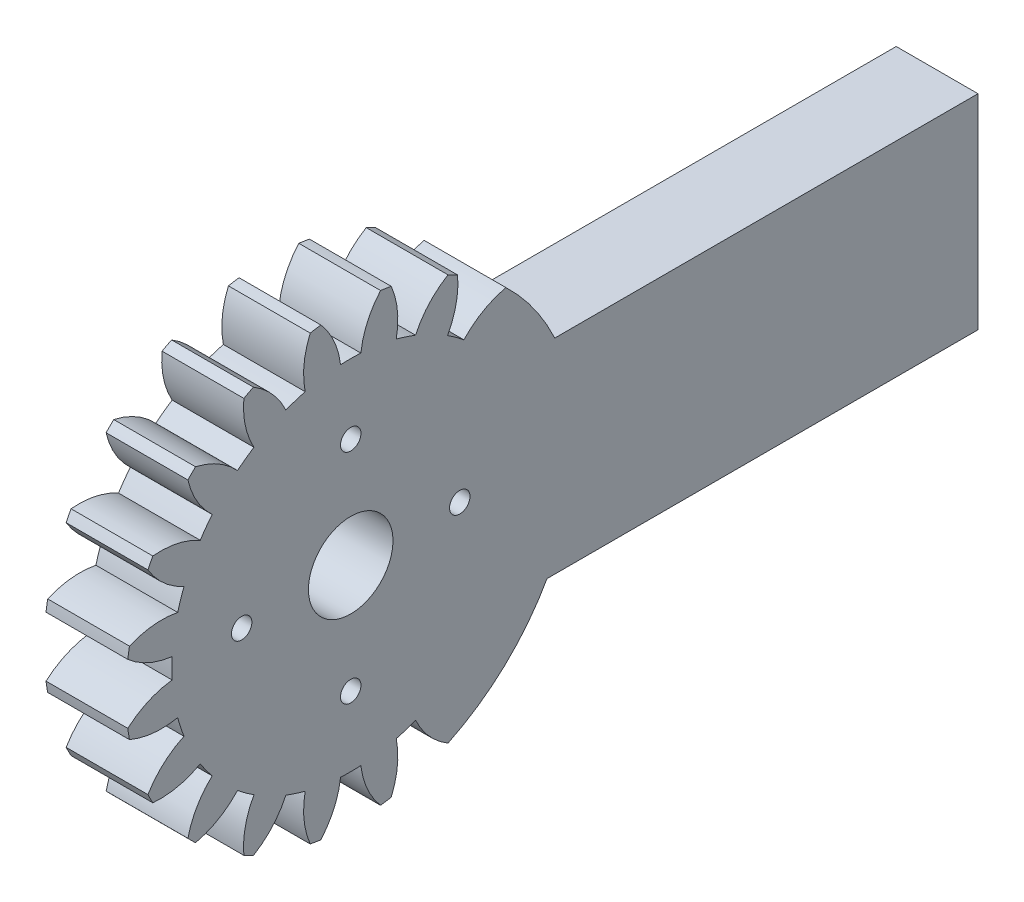
from build123d import *

# Parameters (mm, degrees)
BASPROSKE_W             = 6
BASPROSKE_H             = 16.5
TOOTHCUT_DEPTH          = 25.093567606
TEETHCUTS_COUNT         = 20
TEETHCUTS_ANGLE         = 342
BORSKE_R                = 3.1
BORE_DEPTH              = 50.0000508
ESQUISSE2_W             = 34.6
ESQUISSE2_H             = 15
BOSS_EXTRU_1_DEPTH      = 6
ESQUISSE3_R             = 0.75
ENL_V_MAT_EXTRU_1_DEPTH = 6


with BuildPart() as part:
    # BasProSke → Base-Revolve (revolve)
    with BuildSketch(Plane(origin=(0, 0, 0), x_dir=(1, 0, 0), z_dir=(0, 1, 0)), mode=Mode.PRIVATE) as base_revolve_sk:
        with Locations((3, 8.25)):
            Rectangle(BASPROSKE_W, BASPROSKE_H)
    revolve(base_revolve_sk.sketch.rotate(Axis((-10, 0, 0), (1, 0, 0)), 180), axis=Axis((-10, 0, 0), (1, 0, 0)))

    # TooCutSke → ToothCut (cut, through all)
    with BuildSketch(Plane(origin=(0, 0, 0), x_dir=(0, 0, -1), z_dir=(1, 0, 0))):
        with BuildLine():
            ThreePointArc((0.74381438, 13.102904875), (0, 13.124), (-0.74381438, 13.102904875))
            ThreePointArc((-0.74381438, 13.102904875), (-1.226473103, 14.852072512), (-2.209965745, 16.376962373))
            ThreePointArc((-2.209965745, 16.376962373), (0, 16.5254), (2.209965745, 16.376962373))
            ThreePointArc((2.209965745, 16.376962373), (1.226473103, 14.852072512), (0.74381438, 13.102904875))
        make_face()
    toothcut = extrude(amount=TOOTHCUT_DEPTH, mode=Mode.SUBTRACT)

    # TeethCuts: ToothCut ×20 about axis, 6 skipped
    teethcuts_axis = Axis((-10, 0, 0), (1, 0, 0))
    add([toothcut.rotate(teethcuts_axis, i * TEETHCUTS_ANGLE / (TEETHCUTS_COUNT - 1)) for i in range(1, TEETHCUTS_COUNT) if i not in (12, 13, 14, 15, 16, 17)], mode=Mode.SUBTRACT)

    # BorSke → Bore (cut, symmetric)
    with BuildSketch(Plane(origin=(0, 0, 0), x_dir=(0, 0, -1), z_dir=(1, 0, 0))):
        with Locations(Location((0, 0, 0), (0, 0, 180))):
            Circle(BORSKE_R)
    extrude(amount=BORE_DEPTH, both=True, mode=Mode.SUBTRACT)

    # Esquisse2 → Boss.-Extru.1 (add)
    with BuildSketch(Plane(origin=(6, 0, 0), x_dir=(0, 0, -1), z_dir=(1, 0, 0))):
        with Locations((28.717803782, -0.556420359)):
            Rectangle(ESQUISSE2_W, ESQUISSE2_H)
    extrude(amount=-BOSS_EXTRU_1_DEPTH)

    # Esquisse3 → Enlèv. mat.-Extru.1 (cut)
    with BuildSketch(Plane.ZY):
        with Locations((8, 0)):
            Circle(ESQUISSE3_R)
        with Locations((0, 8)):
            Circle(ESQUISSE3_R)
        with Locations((0, -8)):
            Circle(ESQUISSE3_R)
        with Locations((-8, 0)):
            Circle(ESQUISSE3_R)
    extrude(amount=-ENL_V_MAT_EXTRU_1_DEPTH, mode=Mode.SUBTRACT)


solid = part.part
